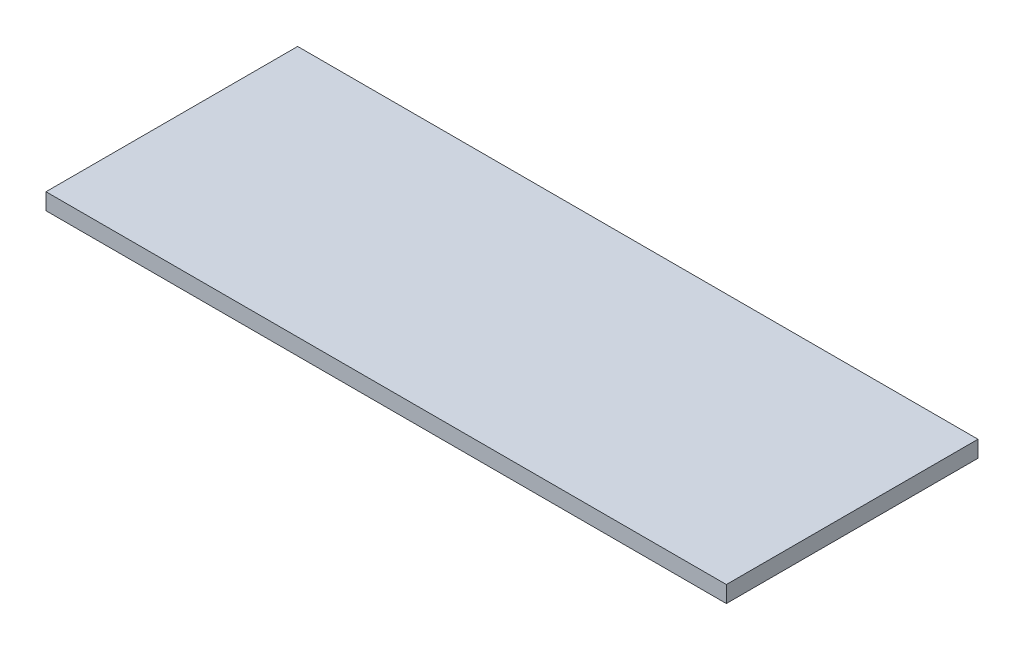
from build123d import *

# Parameters (mm, degrees)
SKETCH1_W      = 66
SKETCH1_H      = 24.412
EXTRUDE1_DEPTH = 1.6


with BuildPart() as part:
    # Sketch1 → Extrude1 (new body)
    with BuildSketch(Plane(origin=(0, 0, 0), x_dir=(1, 0, 0), z_dir=(0, 1, 0))):
        with Locations((33, 12.206)):
            Rectangle(SKETCH1_W, SKETCH1_H)
    extrude(amount=EXTRUDE1_DEPTH)


solid = part.part
